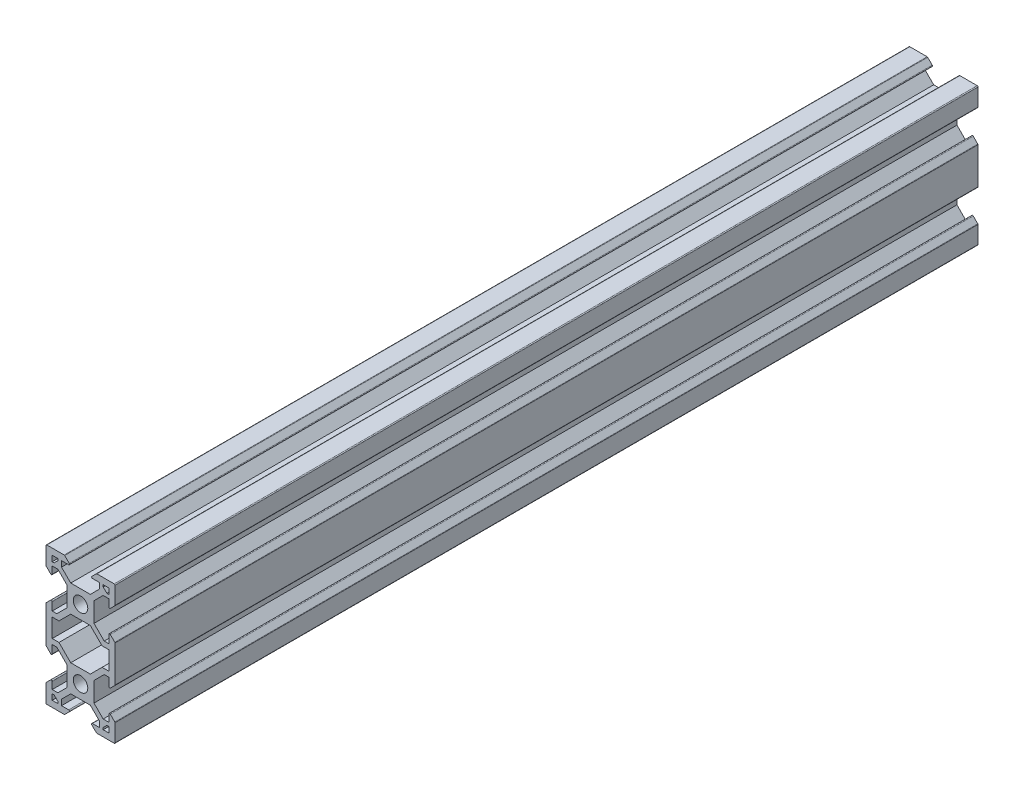
from build123d import *

# Parameters (mm, degrees)
SKETCH1_R            = 2.1
BOSS_EXTRUDE2_DEPTH  = 250
CUT_EXTRUDE1_DEPTH   = 251
FILLET1_R            = 0.25
FILLET1_OF_MIRROR1_R = 0.25


with BuildPart() as part:
    # Sketch1 → Boss-Extrude2 (new body)
    with BuildSketch(Plane.XY):
        Polygon((8.199993721, -10), (9.999993721, -10), (9.999993721, -4.63999575), (8.199993721, -2.84), (8.199993721, -5.800653822), (6.861313026, -5.800653822), (3.900652213, -2.84), (3.900652213, 2.84), (6.559993721, 5.499347787), (8.199993721, 5.499347787), (8.199993721, 2.84), (9.999993721, 4.64000425), (9.999993721, 10), (4.63999575, 10), (2.84, 8.2), (5.499325592, 8.2), (5.499325592, 6.56), (2.84, 3.900668129), (-2.84, 3.900668129), (-5.49933815, 6.56), (-5.49933815, 8.2), (-2.84, 8.2), (-4.64000425, 10), (-10.000006279, 10), (-10.000006279, 4.63999575), (-8.200006279, 2.84), (-8.200006279, 5.499347787), (-6.560006279, 5.499347787), (-3.900652213, 2.84), (-3.900652213, -2.84), (-6.861299044, -5.800653822), (-8.200006279, -5.800653822), (-8.200006279, -2.84), (-10.000006279, -4.64000425), (-10.000006279, -10), (-8.200006279, -10), (-8.200006279, -7.300653822), (-6.239977665, -7.300653822), (-2.84, -3.900668129), (2.84, -3.900668129), (6.239993721, -7.300653822), (8.199993721, -7.300653822), align=None)
        Circle(SKETCH1_R, mode=Mode.SUBTRACT)
    boss_extrude2 = extrude(amount=BOSS_EXTRUDE2_DEPTH)

    # Sketch2 → Cut-Extrude1 (cut, through all)
    with BuildSketch(Plane.XY.offset(250)):
        Polygon((-8.200006279, 6.569347787), (-8.200006279, 8.2), (-6.56933815, 8.2), (-6.56933815, 7.630009211), (-7.62999707, 6.569347787), align=None)
        Polygon((8.199993721, 8.2), (8.199993721, 6.569347787), (7.629987016, 6.569347787), (6.569325592, 7.630006706), (6.569325592, 8.2), align=None)
    cut_extrude1 = extrude(amount=-CUT_EXTRUDE1_DEPTH, mode=Mode.SUBTRACT)

    # Fillet1
    fillet1_edges = [part.edges().sort_by_distance(p)[0] for p in [
        (9.999993721, -4.63999575, 125),
        (-10.000006279, -4.64000425, 125),
        (-8.200006279, -2.84, 125),
        (-8.200006279, 2.84, 125),
        (-10.000006279, 4.63999575, 125),
        (-10.000006279, 10, 125),
        (-4.64000425, 10, 125),
        (-2.84, 8.2, 125),
        (2.84, 8.2, 125),
        (4.63999575, 10, 125),
        (9.999993721, 10, 125),
        (9.999993721, 4.64000425, 125),
        (8.199993721, 2.84, 125),
        (8.199993721, -2.84, 125),
    ]]
    fillet(fillet1_edges, radius=FILLET1_R)

    # Mirror1: Boss-Extrude2 across plane
    add(boss_extrude2.mirror(Plane(origin=(0, -10, 0), x_dir=(0, 0, 1), z_dir=(0, -1, 0))))

    # Fillet1 of Mirror1
    fillet1_of_mirror1_edges = [part.edges().sort_by_distance(p)[0] for p in [
        (9.999993721, -15.36000425, 125),
        (-10.000006279, -15.35999575, 125),
        (-8.200006279, -17.16, 125),
        (-8.200006279, -22.84, 125),
        (-10.000006279, -24.63999575, 125),
        (-10.000006279, -30, 125),
        (-4.64000425, -30, 125),
        (-2.84, -28.2, 125),
        (2.84, -28.2, 125),
        (4.63999575, -30, 125),
        (9.999993721, -30, 125),
        (9.999993721, -24.64000425, 125),
        (8.199993721, -22.84, 125),
        (8.199993721, -17.16, 125),
    ]]
    fillet(fillet1_of_mirror1_edges, radius=FILLET1_OF_MIRROR1_R)

    # Mirror2: Cut-Extrude1 across plane
    add(cut_extrude1.mirror(Plane(origin=(0, -10, 0), x_dir=(0, 0, 1), z_dir=(0, -1, 0))), mode=Mode.SUBTRACT)


solid = part.part
